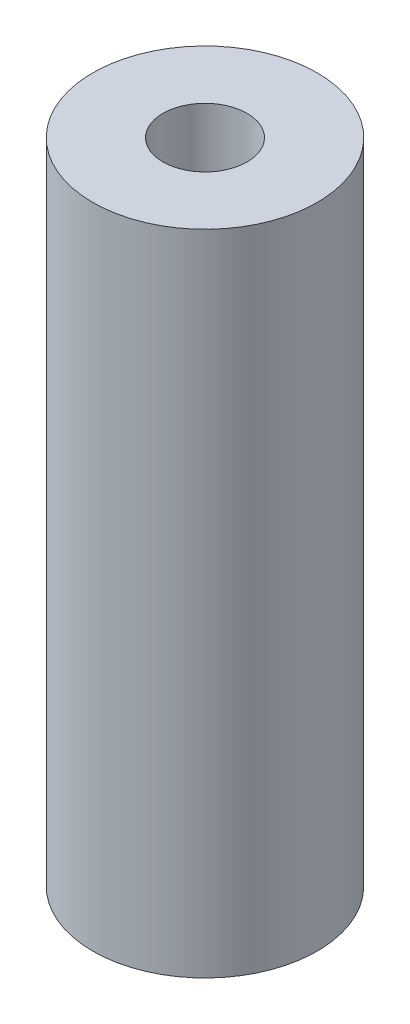
from build123d import *

# Parameters (mm, degrees)
SKETCH1_R           = 12.7
SKETCH1_R_2         = 4.7625
BOSS_EXTRUDE1_DEPTH = 36.6776


with BuildPart() as part:
    # Sketch1 → Boss-Extrude1 (new body, symmetric)
    with BuildSketch(Plane(origin=(0, 0, 0), x_dir=(1, 0, 0), z_dir=(0, 1, 0))):
        Circle(SKETCH1_R)
        Circle(SKETCH1_R_2, mode=Mode.SUBTRACT)
    extrude(amount=BOSS_EXTRUDE1_DEPTH, both=True)


solid = part.part
